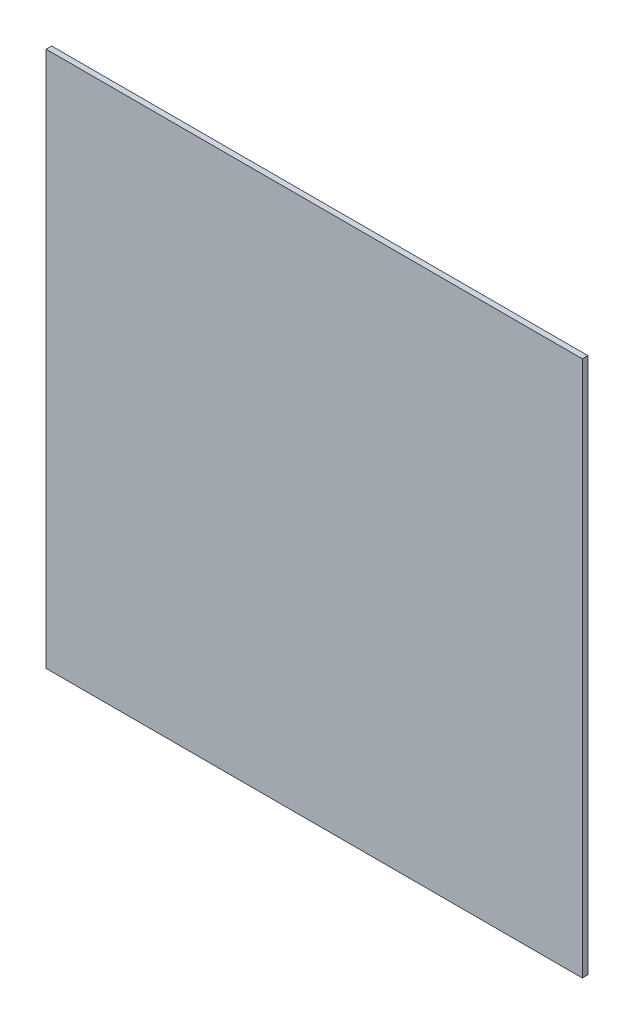
from build123d import *

# Parameters (mm, degrees)
SKETCH1_W           = 304.8
SKETCH1_H           = 304.8
BOSS_EXTRUDE1_DEPTH = 3.175


with BuildPart() as part:
    # Sketch1 → Boss-Extrude1 (new body)
    with BuildSketch(Plane.XY):
        Rectangle(SKETCH1_W, SKETCH1_H)
    extrude(amount=BOSS_EXTRUDE1_DEPTH)


solid = part.part
